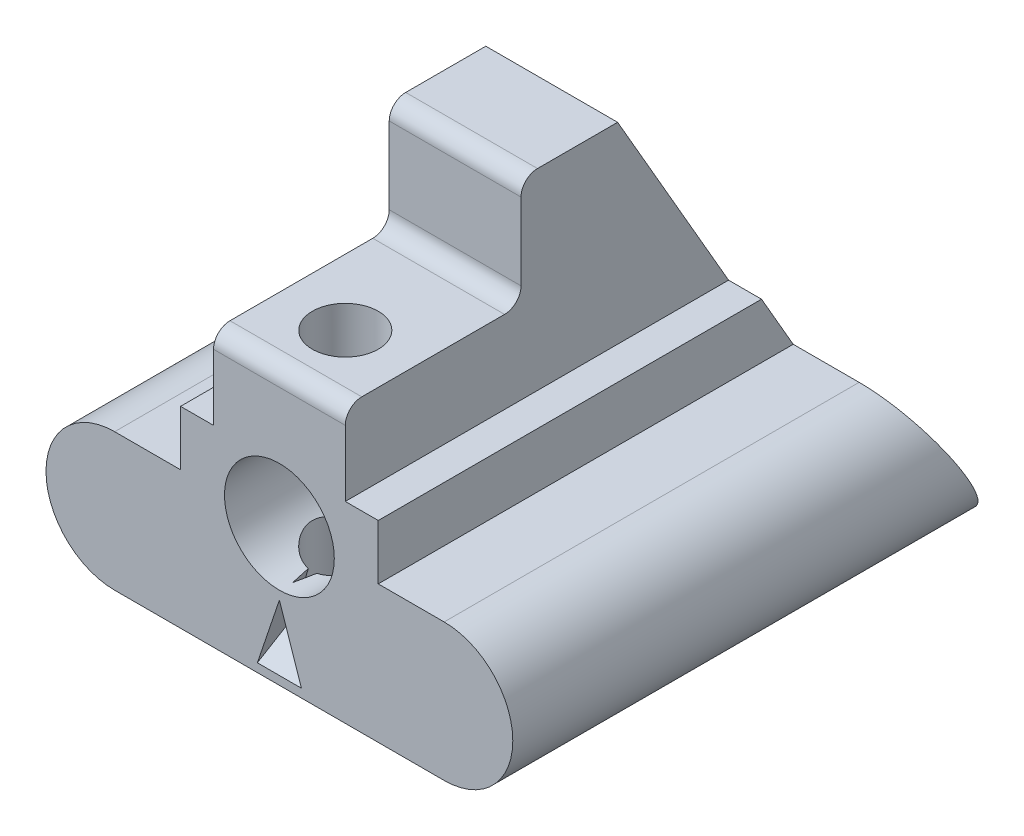
from build123d import *

# Parameters (mm, degrees)
BOSS_EXTRUDE1_DEPTH = 90
CUT_EXTRUDE1_DEPTH  = 90
SKETCH3_W           = 36
SKETCH3_H           = 75.56624327
BOSS_EXTRUDE2_DEPTH = 10
SKETCH4_W           = 24
SKETCH4_H           = 75.56624327
BOSS_EXTRUDE3_DEPTH = 35
SKETCH5_W           = 24
SKETCH5_H           = 32
CUT_EXTRUDE2_DEPTH  = 20
CUT_EXTRUDE3_DEPTH  = 440
SKETCH9_R           = 10
CUT_EXTRUDE6_DEPTH  = 440
SKETCH11_R          = 6
CUT_EXTRUDE7_DEPTH  = 440
CUT_EXTRUDE8_DEPTH  = 440
CUT_EXTRUDE9_DEPTH  = 440
CUT_EXTRUDE10_DEPTH = 89
CUT_EXTRUDE10_TAPER = 1
BOSS_EXTRUDE4_DEPTH = 24


with BuildPart() as part:
    # Sketch1 → Boss-Extrude1 (new body)
    with BuildSketch(Plane.XY):
        with BuildLine():
            Line((-30, 12.5), (30, 12.5))
            ThreePointArc((30, 12.5), (42.5, 0), (30, -12.5))
            Line((30, -12.5), (-30, -12.5))
            ThreePointArc((-30, -12.5), (-42.5, 0), (-30, 12.5))
        make_face()
    extrude(amount=BOSS_EXTRUDE1_DEPTH)

    # Sketch2 → Cut-Extrude1 (cut)
    with BuildSketch(Plane(origin=(42.5, 0, 0), x_dir=(0, 0, -1), z_dir=(1, 0, 0))):
        Polygon((0, -12.5), (-14.43375673, 12.5), (0, 12.5), align=None)
    extrude(amount=-CUT_EXTRUDE1_DEPTH, mode=Mode.SUBTRACT)

    # Sketch3 → Boss-Extrude2 (add)
    with BuildSketch(Plane(origin=(0, 12.5, 0), x_dir=(1, 0, 0), z_dir=(0, 1, 0))):
        with Locations((0, -52.216878365)):
            Rectangle(SKETCH3_W, SKETCH3_H)
    extrude(amount=BOSS_EXTRUDE2_DEPTH)

    # Sketch4 → Boss-Extrude3 (add)
    with BuildSketch(Plane(origin=(0, 22.5, 0), x_dir=(1, 0, 0), z_dir=(0, 1, 0))):
        with Locations((0, -52.216878365)):
            Rectangle(SKETCH4_W, SKETCH4_H)
    extrude(amount=BOSS_EXTRUDE3_DEPTH)

    # Sketch5 → Cut-Extrude2 (cut)
    with BuildSketch(Plane(origin=(0, 57.5, 0), x_dir=(1, 0, 0), z_dir=(0, 1, 0))):
        with Locations((0, -74)):
            Rectangle(SKETCH5_W, SKETCH5_H)
    extrude(amount=-CUT_EXTRUDE2_DEPTH, mode=Mode.SUBTRACT)

    # Sketch6 → Cut-Extrude3 (cut)
    with BuildSketch(Plane(origin=(42.5, 0, 0), x_dir=(0, 0, -1), z_dir=(1, 0, 0))):
        Polygon((-14.43375673, 12.5), (-40.414518843, 57.5), (-14.43375673, 57.5), align=None)
    extrude(amount=-CUT_EXTRUDE3_DEPTH, mode=Mode.SUBTRACT)

    # Sketch9 → Cut-Extrude6 (cut)
    with BuildSketch(Plane.XY.offset(90)):
        with Locations((0, 12.5)):
            Circle(SKETCH9_R)
    extrude(amount=-CUT_EXTRUDE6_DEPTH, mode=Mode.SUBTRACT)

    # Sketch11 → Cut-Extrude7 (cut)
    with BuildSketch(Plane(origin=(0, 37.5, 0), x_dir=(1, 0, 0), z_dir=(0, 1, 0))):
        with Locations((0, -78)):
            Circle(SKETCH11_R)
    extrude(amount=-CUT_EXTRUDE7_DEPTH, mode=Mode.SUBTRACT)

    # Sketch12 → Cut-Extrude8 (cut)
    with BuildSketch(Plane.ZY.offset(12)):
        with BuildLine():
            Line((55, 57.5), (58, 57.5))
            Line((58, 57.5), (58, 54.5))
            ThreePointArc((58, 54.5), (57.121320344, 56.621320344), (55, 57.5))
        make_face()
    extrude(amount=-CUT_EXTRUDE8_DEPTH, mode=Mode.SUBTRACT)

    # Sketch13 → Cut-Extrude9 (cut)
    with BuildSketch(Plane.ZY.offset(12)):
        with BuildLine():
            Line((87, 37.5), (90, 37.5))
            Line((90, 37.5), (90, 34.5))
            ThreePointArc((90, 34.5), (89.121320344, 36.621320344), (87, 37.5))
        make_face()
    extrude(amount=-CUT_EXTRUDE9_DEPTH, mode=Mode.SUBTRACT)

    # Sketch14 → Cut-Extrude10 (cut)
    with BuildSketch(Plane(origin=(0, -3.125, 5.412658774), x_dir=(-1, 0, 0), z_dir=(0, 0.5, -0.866025404))):
        Polygon((-6, 34.174682453), (6, 34.174682453), (0, 49.174682453), align=None)
    extrude(amount=-CUT_EXTRUDE10_DEPTH, taper=CUT_EXTRUDE10_TAPER, mode=Mode.SUBTRACT)

    # Sketch16 → Boss-Extrude4 (add)
    with BuildSketch(Plane(origin=(12, 0, 0), x_dir=(0, 0, -1), z_dir=(1, 0, 0))):
        with BuildLine():
            Line((-61, 37.5), (-58, 37.5))
            Line((-58, 37.5), (-58, 40.5))
            ThreePointArc((-58, 40.5), (-58.878679656, 38.378679656), (-61, 37.5))
        make_face()
    extrude(amount=-BOSS_EXTRUDE4_DEPTH)


solid = part.part
